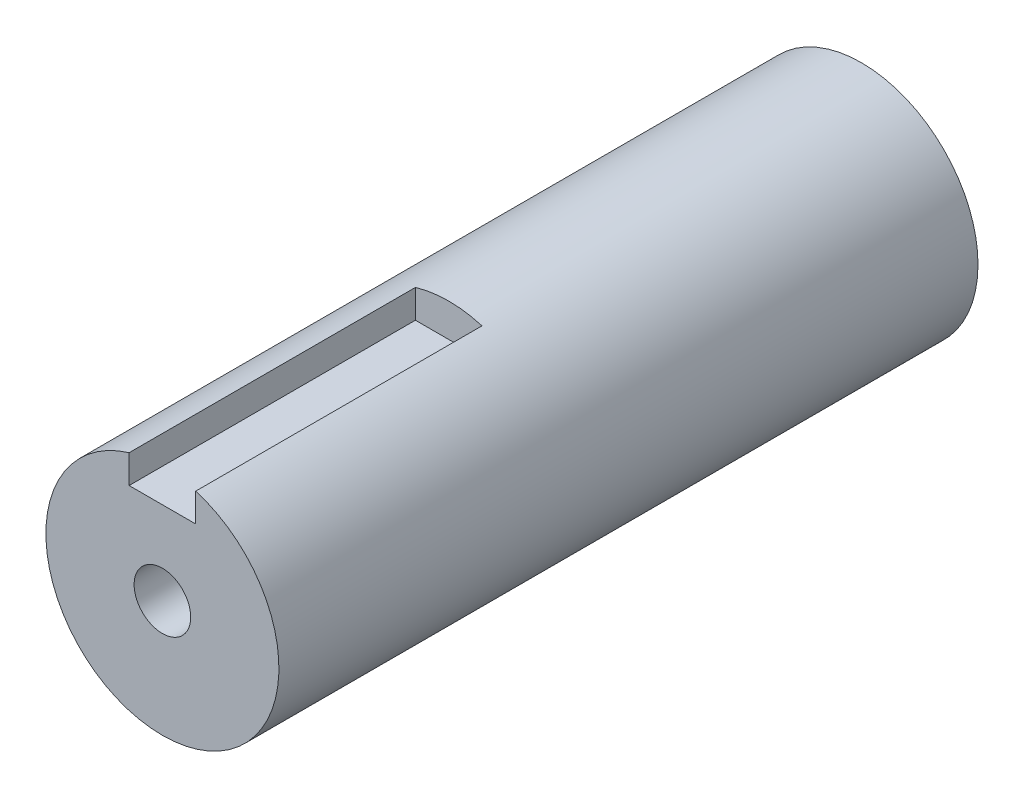
from build123d import *

# Parameters (mm, degrees)
ESQUISSE1_R             = 17.5
BOSS_EXTRU_1_DEPTH      = 105
ESQUISSE2_W             = 10
ESQUISSE2_H             = 7.08484742
ENL_V_MAT_EXTRU_1_DEPTH = 43
TROU_TARAUD_M101_D      = 8.5
TROU_TARAUD_M101_DEPTH  = 40
TROU_TARAUD_M101_TIP    = 2.553657631


with BuildPart() as part:
    # Esquisse1 → Boss.-Extru.1 (new body)
    with BuildSketch(Plane.XY):
        Circle(ESQUISSE1_R)
    extrude(amount=BOSS_EXTRU_1_DEPTH)

    # Esquisse2 → Enlèv. mat.-Extru.1 (cut)
    with BuildSketch(Plane.XY.offset(105)):
        with Locations((0, 16.04242371)):
            Rectangle(ESQUISSE2_W, ESQUISSE2_H)
    extrude(amount=-ENL_V_MAT_EXTRU_1_DEPTH, mode=Mode.SUBTRACT)

    # Trou taraudé M101
    with Locations(Plane.XY.offset(105)):
        with Locations((0, 0)):
            Hole(TROU_TARAUD_M101_D / 2, depth=TROU_TARAUD_M101_DEPTH)
            with Locations((0, 0, -(TROU_TARAUD_M101_DEPTH + TROU_TARAUD_M101_TIP / 2))):  # 118° drill point
                Cone(0, TROU_TARAUD_M101_D / 2, TROU_TARAUD_M101_TIP, mode=Mode.SUBTRACT)


solid = part.part
